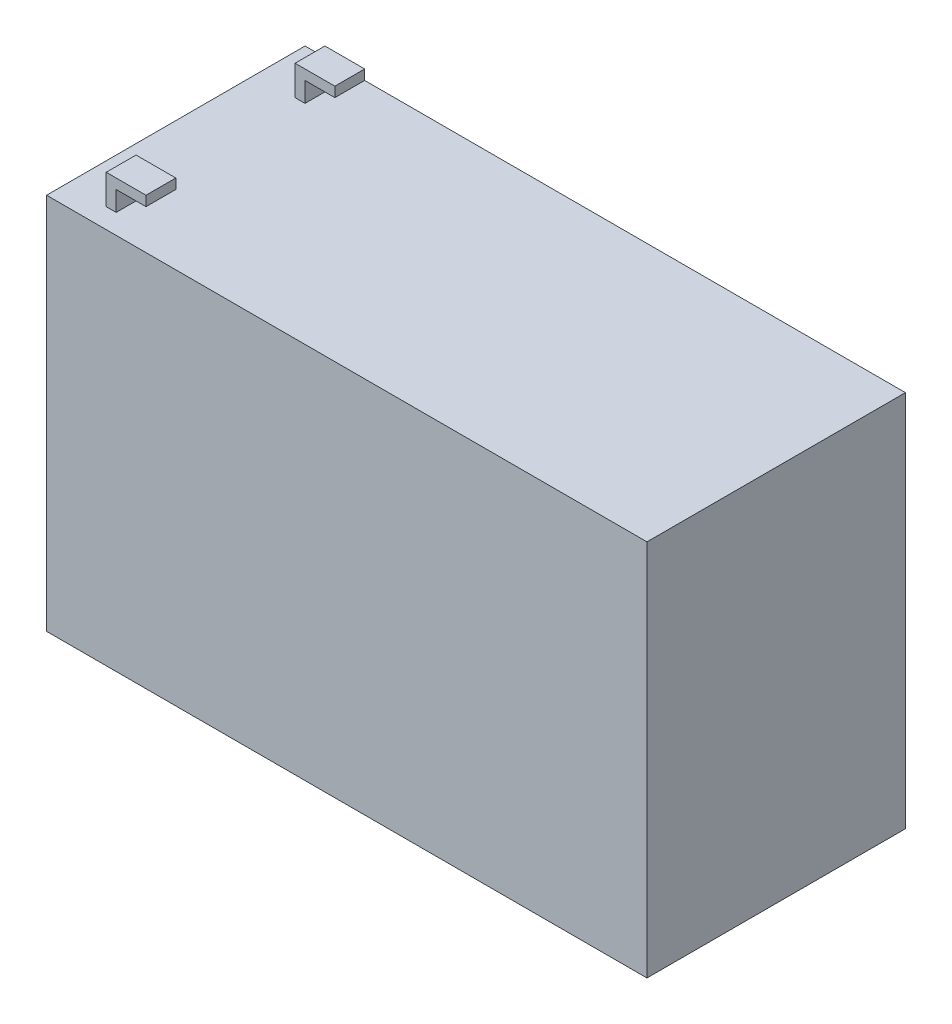
from build123d import *

# Parameters (mm, degrees)
SKETCH1_W           = 151
SKETCH1_H           = 95
BOSS_EXTRUDE1_DEPTH = 65
BOSS_EXTRUDE2_DEPTH = 65
CUT_EXTRUDE1_REACH  = 143
SKETCH3_W           = 5
SKETCH3_H           = 7.5
SKETCH3_W_2         = 40


with BuildPart() as part:
    # Sketch1 → Boss-Extrude1 (new body)
    with BuildSketch(Plane.XY):
        Rectangle(SKETCH1_W, SKETCH1_H)
    extrude(amount=-BOSS_EXTRUDE1_DEPTH)

    # Sketch2 → Boss-Extrude2 (add)
    with BuildSketch(Plane.XY):
        Polygon((-65.5, 47.5), (-65.5, 55), (-55.5, 55), (-55.5, 52.5), (-63, 52.5), (-63, 47.5), align=None)
    extrude(amount=-BOSS_EXTRUDE2_DEPTH)

    # Sketch3 → Cut-Extrude1 (cut, up to next)
    with BuildSketch(Plane.ZY.offset(65.5), mode=Mode.PRIVATE) as cut_extrude1_sk1:
        with Locations((-62.5, 51.25)):
            Rectangle(SKETCH3_W, SKETCH3_H)
    cut_extrude1_tool1 = extrude(cut_extrude1_sk1.sketch, amount=-CUT_EXTRUDE1_REACH, mode=Mode.PRIVATE) & part.part
    add(cut_extrude1_tool1.solids().sort_by_distance((-65.5, 51.25, -62.5))[0], mode=Mode.SUBTRACT)
    # Sketch3 → Cut-Extrude1 (cut, up to next)
    with BuildSketch(Plane.ZY.offset(65.5), mode=Mode.PRIVATE) as cut_extrude1_sk2:
        with Locations((-32.5, 51.25)):
            Rectangle(SKETCH3_W_2, SKETCH3_H)
    cut_extrude1_tool2 = extrude(cut_extrude1_sk2.sketch, amount=-CUT_EXTRUDE1_REACH, mode=Mode.PRIVATE) & part.part
    add(cut_extrude1_tool2.solids().sort_by_distance((-65.5, 51.25, -32.5))[0], mode=Mode.SUBTRACT)
    # Sketch3 → Cut-Extrude1 (cut, up to next)
    with BuildSketch(Plane.ZY.offset(65.5), mode=Mode.PRIVATE) as cut_extrude1_sk3:
        with Locations((-2.5, 51.25)):
            Rectangle(SKETCH3_W, SKETCH3_H)
    cut_extrude1_tool3 = extrude(cut_extrude1_sk3.sketch, amount=-CUT_EXTRUDE1_REACH, mode=Mode.PRIVATE) & part.part
    add(cut_extrude1_tool3.solids().sort_by_distance((-65.5, 51.25, -2.5))[0], mode=Mode.SUBTRACT)


solid = part.part
